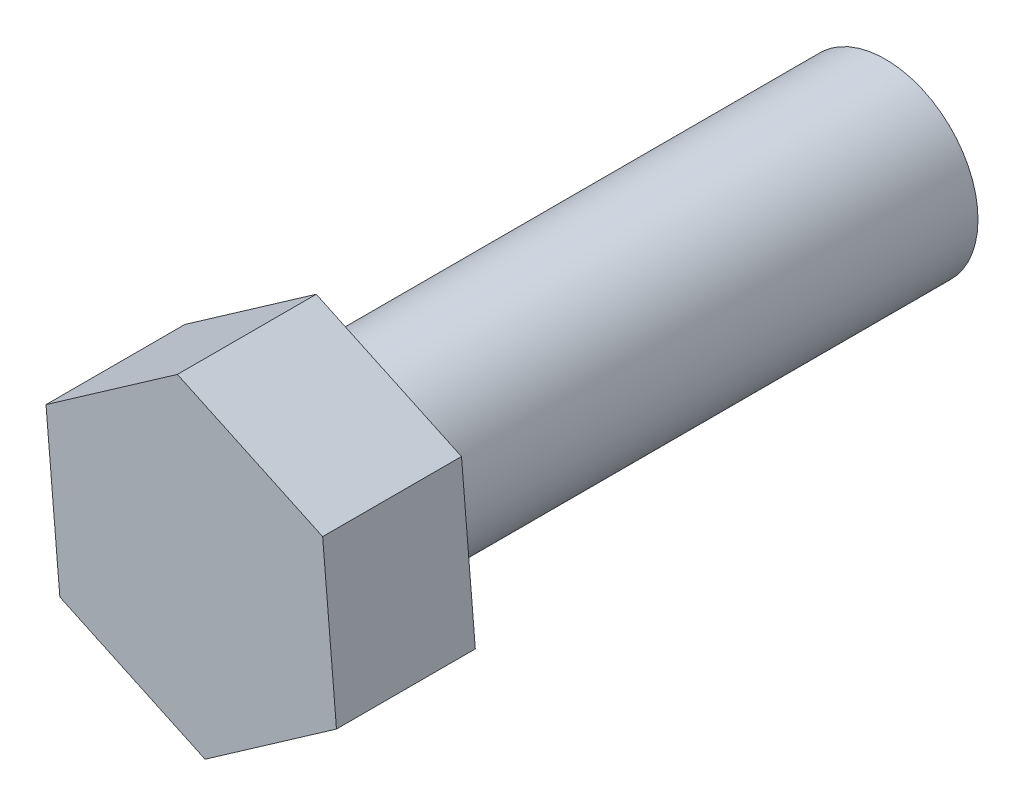
from build123d import *

# Parameters (mm, degrees)
EXTRUDE_1_DEPTH = 3
SKETCH_2_R      = 2
EXTRUDE_2_DEPTH = 12


with BuildPart() as part:
    # 草图1 → 凸台-拉伸1 (new body)
    with BuildSketch(Plane.XY):
        Polygon((0.299200272, -3.451156212), (3.138389088, -1.466463069), (2.839188816, 1.984693142), (-0.299200272, 3.451156212), (-3.138389088, 1.466463069), (-2.839188816, -1.984693142), align=None)
    extrude(amount=EXTRUDE_1_DEPTH)

    # 草图2 → 凸台-拉伸2 (add)
    with BuildSketch(Plane(origin=(0, 0, 0), x_dir=(-1, 0, 0), z_dir=(0, 0, -1))):
        Circle(SKETCH_2_R)
    extrude(amount=EXTRUDE_2_DEPTH)


solid = part.part
